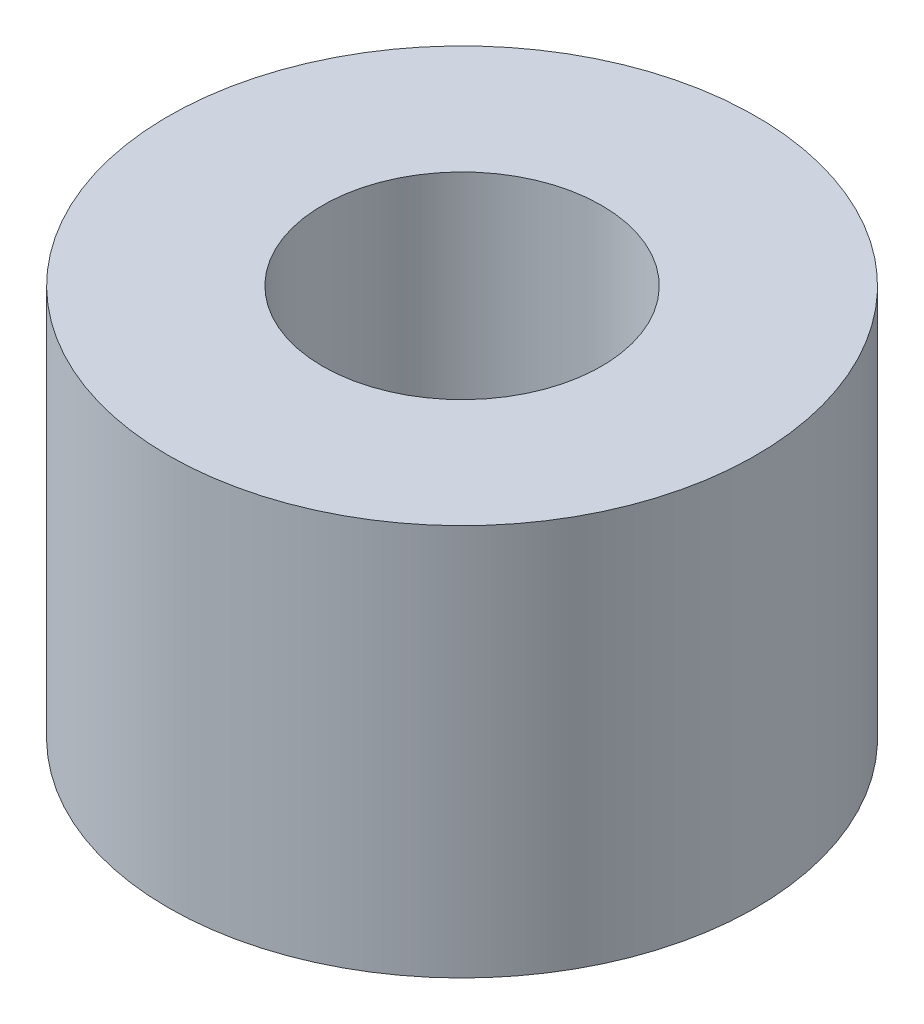
from build123d import *

# Parameters (mm, degrees)
SKETCH1_R                     = 2.38125
BOSS_EXTRUDE1_DEPTH           = 3.175
TAP_DRILL_FOR_4_40_TAP1_D     = 2.2606
TAP_DRILL_FOR_4_40_TAP1_DEPTH = 3.302
TAP_DRILL_FOR_4_40_TAP1_TIP   = 0.679152758


with BuildPart() as part:
    # Sketch1 → Boss-Extrude1 (new body)
    with BuildSketch(Plane(origin=(0, 0, 0), x_dir=(1, 0, 0), z_dir=(0, 1, 0))):
        Circle(SKETCH1_R)
    extrude(amount=BOSS_EXTRUDE1_DEPTH)

    # Tap Drill for #4-40 Tap1
    with Locations(Plane(origin=(0, 3.175, 0), x_dir=(-1, 0, 0), z_dir=(0, 1, 0))):
        with Locations((0, 0)):
            Hole(TAP_DRILL_FOR_4_40_TAP1_D / 2, depth=TAP_DRILL_FOR_4_40_TAP1_DEPTH)
            with Locations((0, 0, -(TAP_DRILL_FOR_4_40_TAP1_DEPTH + TAP_DRILL_FOR_4_40_TAP1_TIP / 2))):  # 118° drill point
                Cone(0, TAP_DRILL_FOR_4_40_TAP1_D / 2, TAP_DRILL_FOR_4_40_TAP1_TIP, mode=Mode.SUBTRACT)


solid = part.part
